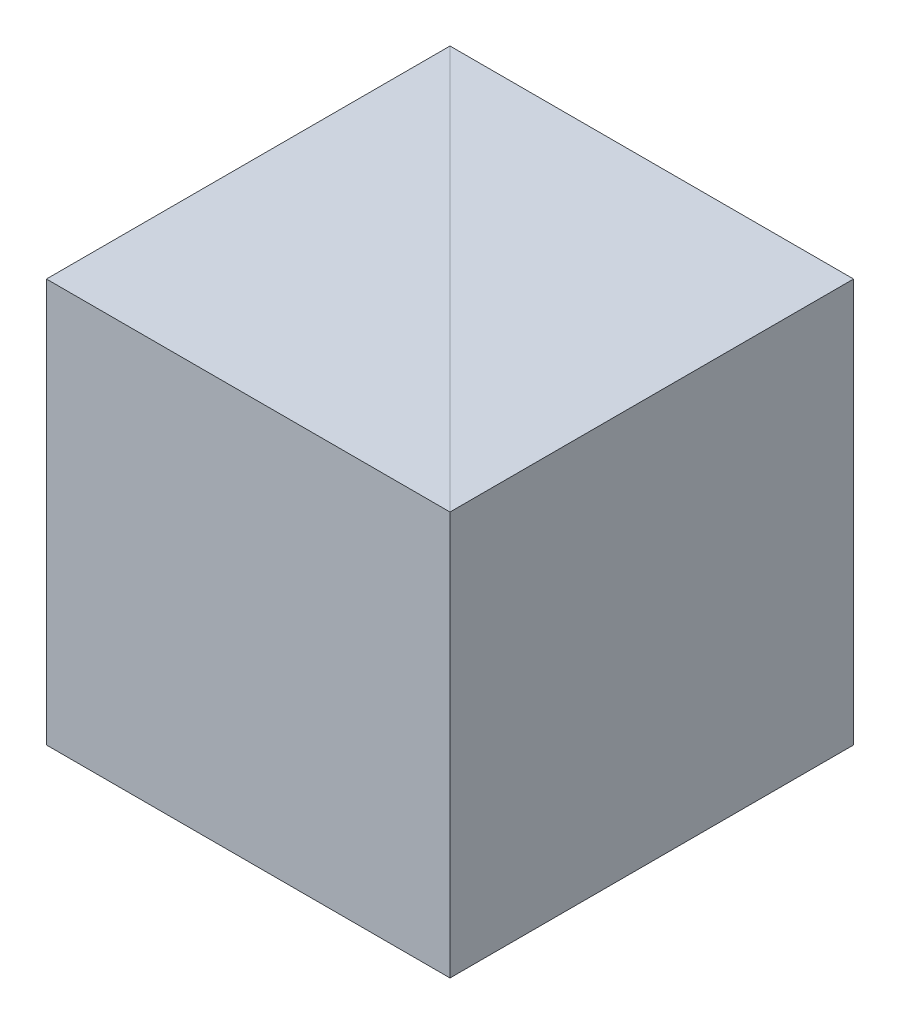
from build123d import *

# Parameters (mm, degrees)
EXTRUDE_1_DEPTH = 5
EXTRUDE_2_DEPTH = 5


with BuildPart() as part:
    # 草图1 → 凸台-拉伸1 (new body)
    with BuildSketch(Plane(origin=(0, 0, 0), x_dir=(1, 0, 0), z_dir=(0, 1, 0))):
        Polygon((0, 0), (0, 5), (-5, 5), align=None)
    extrude(amount=EXTRUDE_1_DEPTH)


with BuildPart() as body_2:
    # 草图2 → 凸台-拉伸2 (new body)
    with BuildSketch(Plane.XZ):
        Polygon((-5, -5), (-5, 0), (0, 0), align=None)
    extrude(amount=-EXTRUDE_2_DEPTH)


solid = Compound([part.part, body_2.part])
